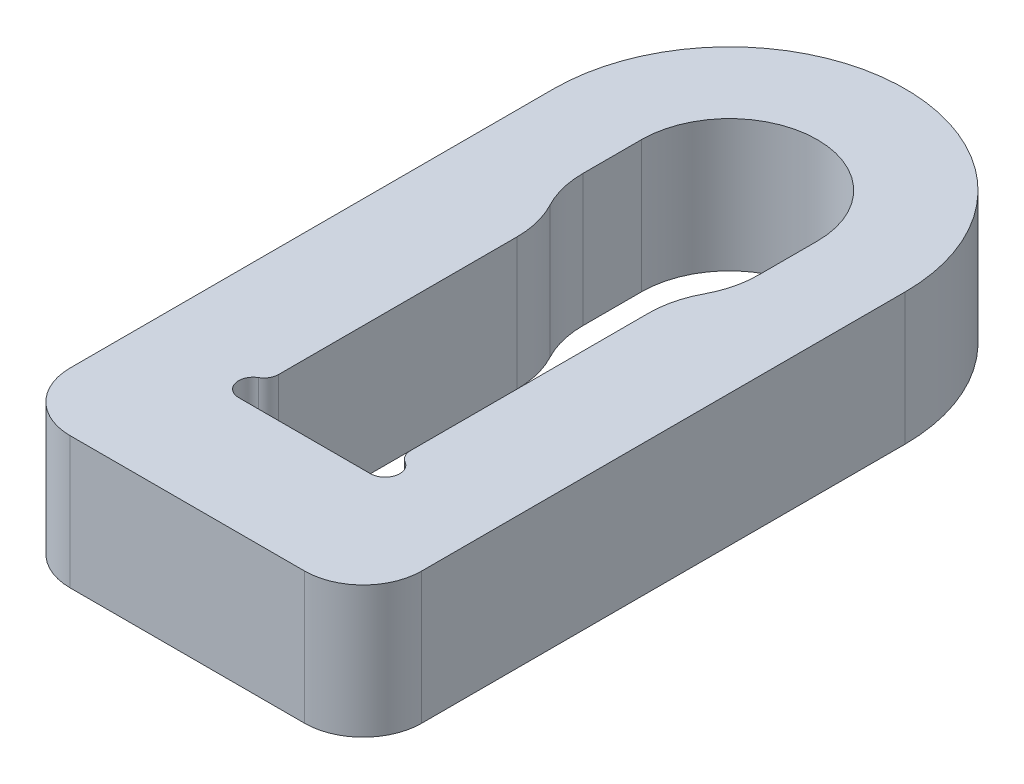
from build123d import *

# Parameters (mm, degrees)
BOSS_EXTRUDE1_DEPTH = 4.5


with BuildPart() as part:
    # Sketch1 → Boss-Extrude1 (new body)
    with BuildSketch(Plane(origin=(0, 0, 0), x_dir=(1, 0, 0), z_dir=(0, 1, 0))):
        with BuildLine():
            Line((-6, 0), (-6, -5))
            Line((-6, -5), (-6, -16.5))
            ThreePointArc((-6, -16.5), (-5.414213562, -17.914213562), (-4, -18.5))
            Line((-4, -18.5), (4, -18.5))
            ThreePointArc((4, -18.5), (5.414213562, -17.914213562), (6, -16.5))
            Line((6, -16.5), (6, -5))
            Line((6, -5), (6, 0))
            ThreePointArc((6, 0), (0, 6), (-6, 0))
        make_face()
        with BuildLine():
            Line((3, 0), (3, -2))
            ThreePointArc((3, -2), (2.904829219, -2.773082305), (2.625, -3.5))
            ThreePointArc((2.625, -3.5), (2.345170781, -4.226917695), (2.25, -5))
            Line((2.25, -5), (2.25, -13.133974596))
            ThreePointArc((2.25, -13.133974596), (2.316987298, -13.383974596), (2.5, -13.566987298))
            ThreePointArc((2.5, -13.566987298), (2.732962913, -14.129409523), (2.25, -14.5))
            Line((2.25, -14.5), (-2.25, -14.5))
            ThreePointArc((-2.25, -14.5), (-2.732962913, -14.129409523), (-2.5, -13.566987298))
            ThreePointArc((-2.5, -13.566987298), (-2.316987298, -13.383974596), (-2.25, -13.133974596))
            Line((-2.25, -13.133974596), (-2.25, -5))
            ThreePointArc((-2.25, -5), (-2.345170781, -4.226917695), (-2.625, -3.5))
            ThreePointArc((-2.625, -3.5), (-2.904829219, -2.773082305), (-3, -2))
            Line((-3, -2), (-3, 0))
            ThreePointArc((-3, 0), (0, 3), (3, 0))
        make_face(mode=Mode.SUBTRACT)
    extrude(amount=BOSS_EXTRUDE1_DEPTH)


solid = part.part
